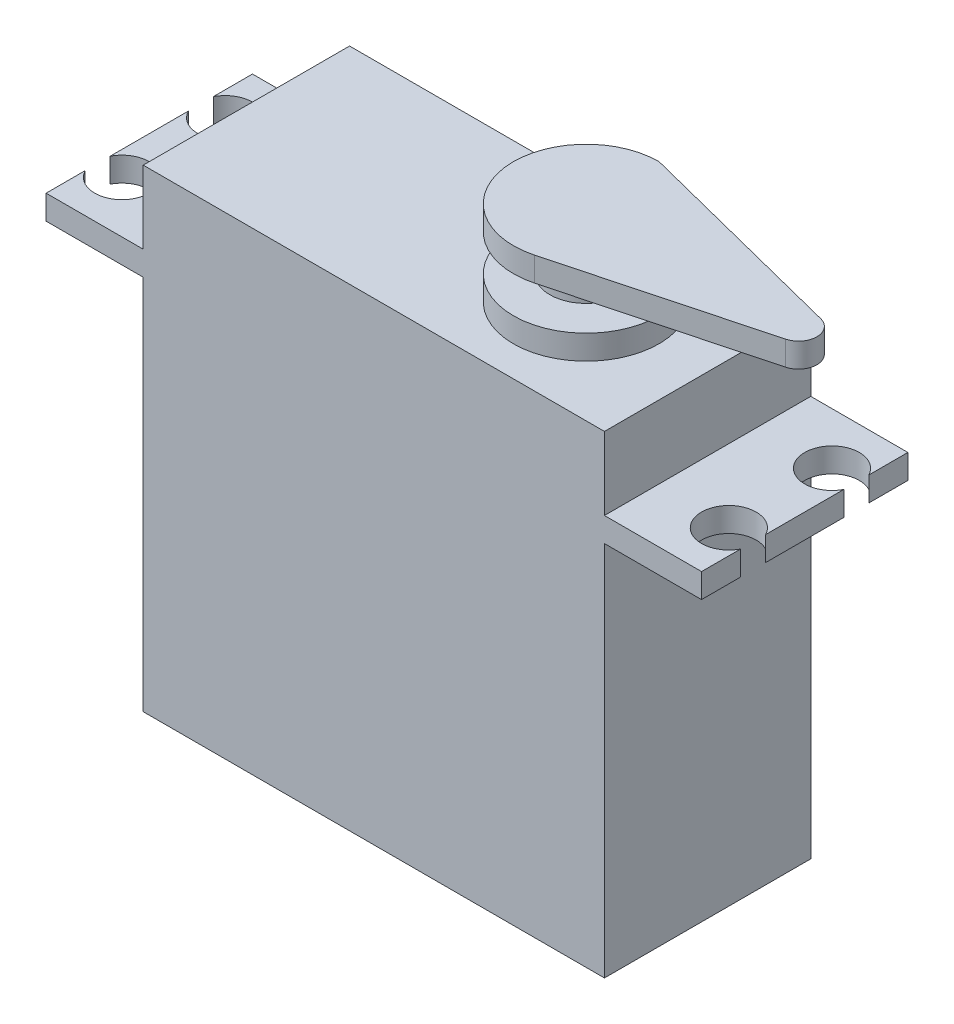
from build123d import *

# Parameters (mm, degrees)
SKETCH1_W           = 38
SKETCH1_H           = 17
BOSS_EXTRUDE1_DEPTH = 39
BOSS_EXTRUDE2_DEPTH = 2
SKETCH3_R           = 6
BOSS_EXTRUDE3_DEPTH = 2
SKETCH4_R           = 3
BOSS_EXTRUDE4_DEPTH = 3
BOSS_EXTRUDE5_DEPTH = 2


with BuildPart() as part:
    # Sketch1 → Boss-Extrude1 (new body)
    with BuildSketch(Plane(origin=(0, 0, 0), x_dir=(1, 0, 0), z_dir=(0, 1, 0))):
        Rectangle(SKETCH1_W, SKETCH1_H)
    extrude(amount=BOSS_EXTRUDE1_DEPTH)

    # Sketch2 → Boss-Extrude2 (add)
    with BuildSketch(Plane(origin=(0, 31, 0), x_dir=(1, 0, 0), z_dir=(0, 1, 0))):
        with BuildLine():
            Line((19, 8.5), (27, 8.5))
            Line((27, 8.5), (27, 5.280776406))
            ThreePointArc((27, 5.280776406), (22.75, 4.25), (27, 3.219223594))
            Line((27, 3.219223594), (27, -3.219223594))
            ThreePointArc((27, -3.219223594), (22.75, -4.25), (27, -5.280776406))
            Line((27, -5.280776406), (27, -8.5))
            Line((27, -8.5), (19, -8.5))
            Line((19, -8.5), (19, 8.5))
        make_face()
    boss_extrude2 = extrude(amount=BOSS_EXTRUDE2_DEPTH)

    # Mirror1: Boss-Extrude2 across plane
    add(boss_extrude2.mirror(Plane(origin=(0, 0, 0), x_dir=(0, 0, 1), z_dir=(1, 0, 0))))

    # Sketch3 → Boss-Extrude3 (add)
    with BuildSketch(Plane(origin=(0, 39, 0), x_dir=(1, 0, 0), z_dir=(0, 1, 0))):
        with Locations((9, 0)):
            Circle(SKETCH3_R)
    extrude(amount=BOSS_EXTRUDE3_DEPTH)

    # Sketch4 → Boss-Extrude4 (add)
    with BuildSketch(Plane(origin=(0, 41, 0), x_dir=(1, 0, 0), z_dir=(0, 1, 0))):
        with Locations((9, 0)):
            Circle(SKETCH4_R)
    extrude(amount=BOSS_EXTRUDE4_DEPTH)

    # Sketch5 → Boss-Extrude5 (add)
    with BuildSketch(Plane(origin=(0, 44, 0), x_dir=(1, 0, 0), z_dir=(0, 1, 0))):
        with BuildLine():
            Line((9, 6), (26.869837254, 1.453691991))
            ThreePointArc((26.869837254, 1.453691991), (27.99997757, 0.008202936), (26.885714286, -1.449560102))
            Line((26.885714286, -1.449560102), (10.542857143, -5.798240409))
            ThreePointArc((10.542857143, -5.798240409), (3.050653714, -0.777996641), (9, 6))
        make_face()
    extrude(amount=BOSS_EXTRUDE5_DEPTH)


solid = part.part
